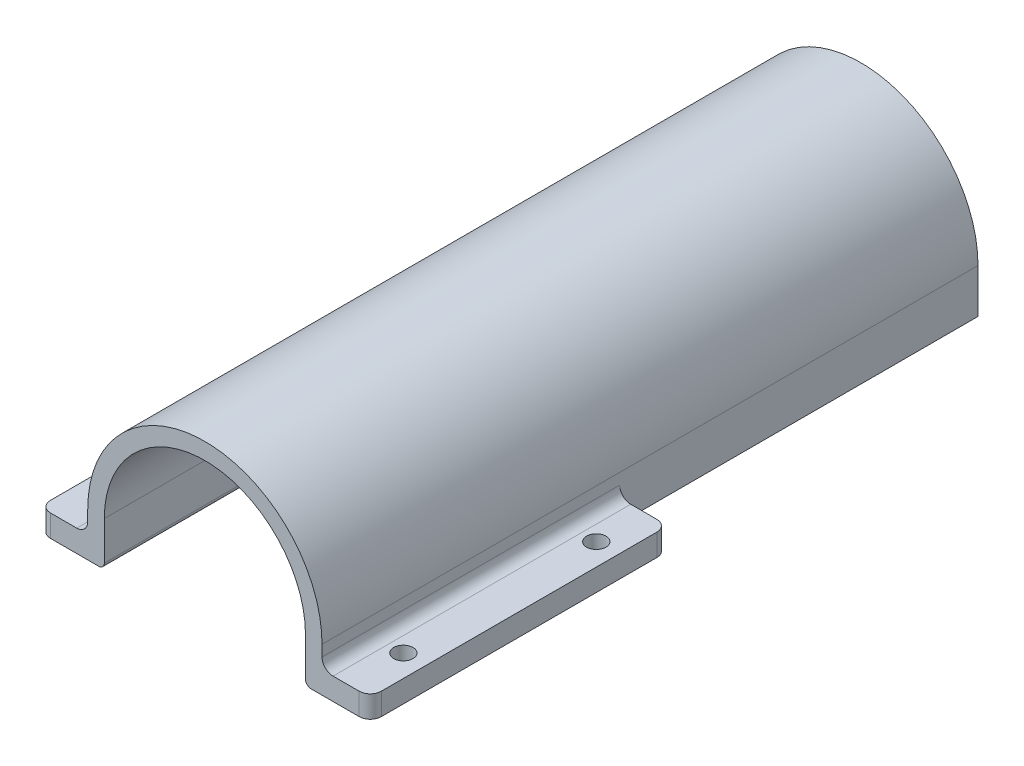
from build123d import *

# Parameters (mm, degrees)
EXTRUDE_5_DEPTH     = 54
SKETCH_10_OUTSIDE_W = 79.172
SKETCH_10_OUTSIDE_H = 73.172
SKETCH_10_OUTSIDE_R = 1.75
CUT_EXTRUDE_1_DEPTH = 4
FILLET_1_R          = 1
EXTRUDE_6_DEPTH     = 65
EXTRUDE_7_DEPTH     = 2


with BuildPart() as part:
    # Sketch 11 → Extrude 5 (new body)
    with BuildSketch(Plane.XY):
        with BuildLine():
            Line((-30, 0), (-30, 4))
            Line((-30, 4), (-23.25, 4))
            ThreePointArc((-23.25, 4), (-21.835786438, 4.585786438), (-21.25, 6))
            Line((-21.25, 6), (-21.25, 8))
            ThreePointArc((-21.25, 8), (0, 29.25), (21.25, 8))
            Line((21.25, 8), (21.25, 6))
            ThreePointArc((21.25, 6), (21.835786438, 4.585786438), (23.25, 4))
            Line((23.25, 4), (30, 4))
            Line((30, 4), (30, 0))
            Line((30, 0), (18.25, 0))
            Line((18.25, 0), (18.25, 8))
            ThreePointArc((18.25, 8), (0, 26.25), (-18.25, 8))
            Line((-18.25, 8), (-18.25, 0))
            Line((-18.25, 0), (-30, 0))
        make_face()
    extrude(amount=EXTRUDE_5_DEPTH)

    # Sketch 10 outside → Cut-Extrude 1 (cut)
    with BuildSketch(Plane(origin=(0, 0, 0), x_dir=(1, 0, 0), z_dir=(0, 1, 0))):
        with Locations((0, -27)):
            Rectangle(SKETCH_10_OUTSIDE_W, SKETCH_10_OUTSIDE_H)
        with BuildLine():
            Line((-30, -2), (-30, -52))
            ThreePointArc((-30, -52), (-29.414213562, -53.414213562), (-28, -54))
            Line((-28, -54), (28, -54))
            ThreePointArc((28, -54), (29.414213562, -53.414213562), (30, -52))
            Line((30, -52), (30, -2))
            ThreePointArc((30, -2), (29.414213562, -0.585786438), (28, 0))
            Line((28, 0), (-28, 0))
            ThreePointArc((-28, 0), (-29.414213562, -0.585786438), (-30, -2))
        make_face(mode=Mode.SUBTRACT)
        with Locations((-26, -9)):
            Circle(SKETCH_10_OUTSIDE_R)
        with Locations((26, -9)):
            Circle(SKETCH_10_OUTSIDE_R)
        with Locations((26, -44)):
            Circle(SKETCH_10_OUTSIDE_R)
        with Locations((-26, -44)):
            Circle(SKETCH_10_OUTSIDE_R)
    extrude(amount=CUT_EXTRUDE_1_DEPTH, mode=Mode.SUBTRACT)

    # Fillet 1
    fillet_1_edges = [part.edges().sort_by_distance(p)[0] for p in [
        (18.25, 0, 27),
        (-18.25, 0, 27),
    ]]
    fillet(fillet_1_edges, radius=FILLET_1_R)

    # Sketch 12 → Extrude 6 (add)
    with BuildSketch(Plane(origin=(0, 0, 0), x_dir=(-1, 0, 0), z_dir=(0, 0, -1))):
        with BuildLine():
            ThreePointArc((-18.25, 8), (0, 26.25), (18.25, 8))
            Line((18.25, 8), (18.25, 6))
            Line((18.25, 6), (18.25, 1))
            ThreePointArc((18.25, 1), (18.542893219, 0.292893219), (19.25, 0))
            Line((19.25, 0), (21.25, 0))
            Line((21.25, 0), (21.25, 6))
            Line((21.25, 6), (21.25, 8))
            ThreePointArc((21.25, 8), (0, 29.25), (-21.25, 8))
            Line((-21.25, 8), (-21.25, 6))
            Line((-21.25, 6), (-21.25, 0))
            Line((-21.25, 0), (-19.25, 0))
            ThreePointArc((-19.25, 0), (-18.542893219, 0.292893219), (-18.25, 1))
            Line((-18.25, 1), (-18.25, 6))
            Line((-18.25, 6), (-18.25, 8))
        make_face()
    extrude(amount=EXTRUDE_6_DEPTH)

    # Sketch 13 → Extrude 7 (add)
    with BuildSketch(Plane(origin=(0, 0, -65), x_dir=(-1, 0, 0), z_dir=(0, 0, -1))):
        with BuildLine():
            Line((-18.25, 1), (18.25, 1))
            Line((18.25, 1), (18.25, 8))
            ThreePointArc((18.25, 8), (0, 26.25), (-18.25, 8))
            Line((-18.25, 8), (-18.25, 1))
        make_face()
    extrude(amount=-EXTRUDE_7_DEPTH)


solid = part.part
